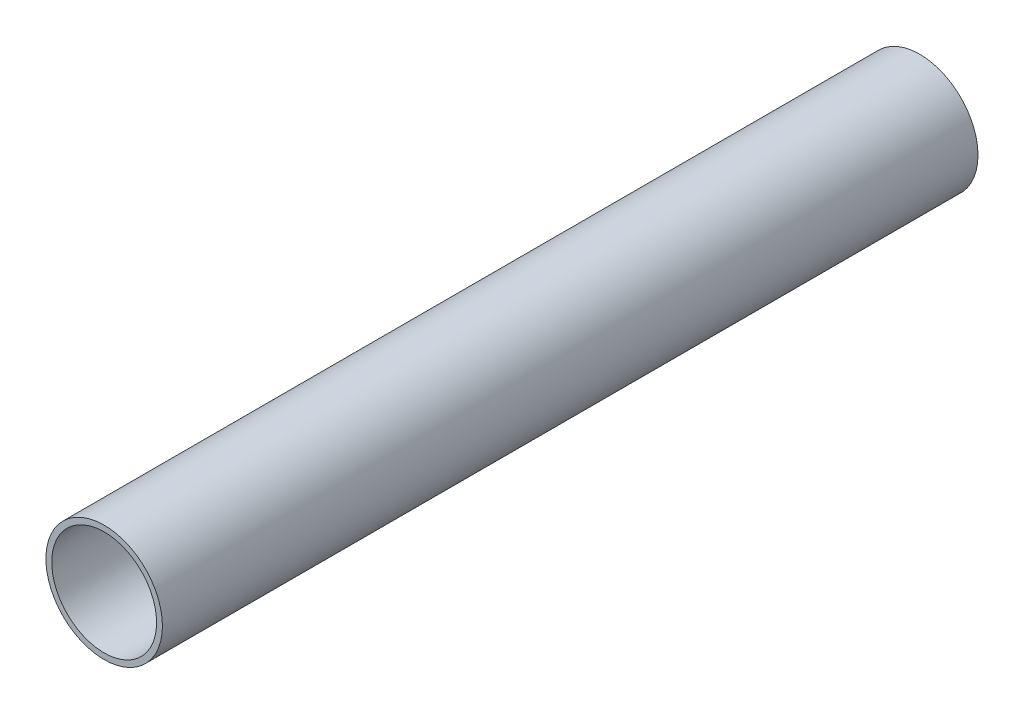
from build123d import *

# Parameters (mm, degrees)
SKETCH3_R           = 10
SKETCH3_R_2         = 9
EXTRUDE_THIN2_DEPTH = 140


with BuildPart() as part:
    # Sketch3 → Extrude-Thin2 (new body)
    with BuildSketch(Plane.XY):
        Circle(SKETCH3_R)
        Circle(SKETCH3_R_2, mode=Mode.SUBTRACT)
    extrude(amount=EXTRUDE_THIN2_DEPTH)


solid = part.part
